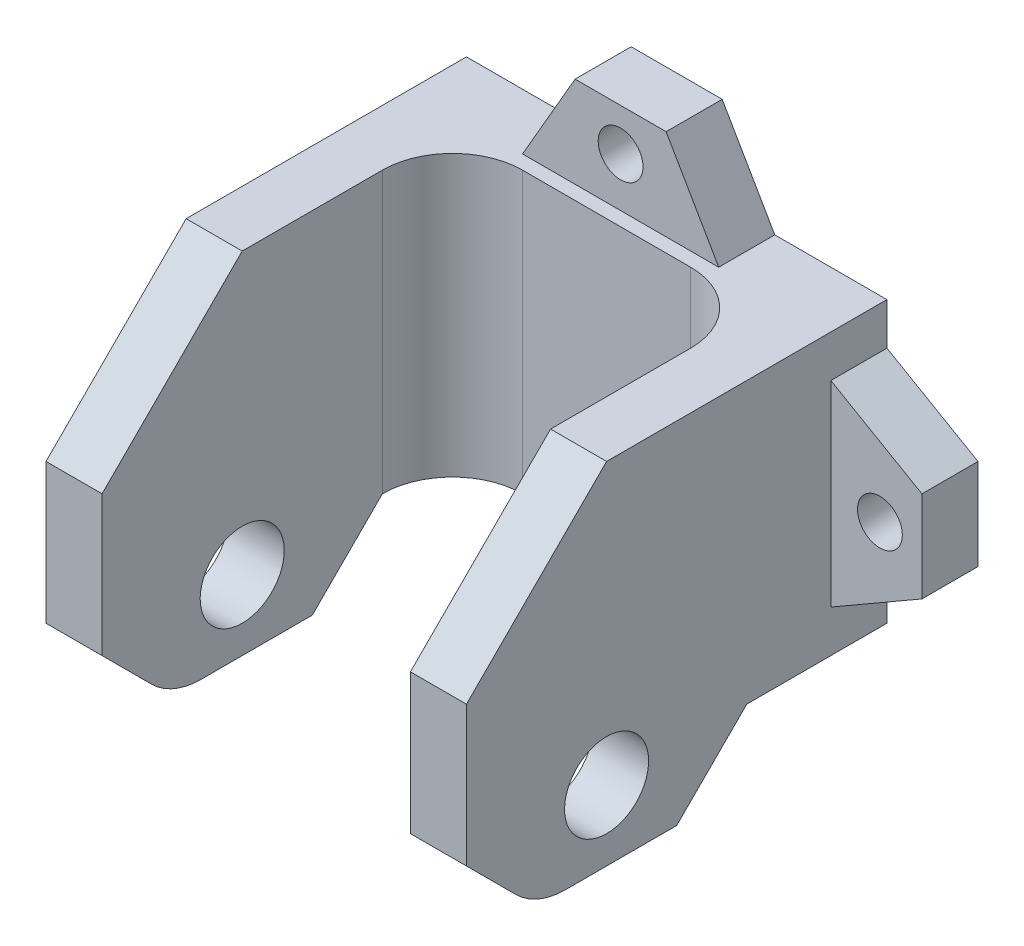
from build123d import *

# Parameters (mm, degrees)
SKETCH1_W             = 30
SKETCH1_H             = 40
BOSS_EXTRUDE1_DEPTH   = 5
SKETCH2_W             = 4
SKETCH2_H             = 40
BOSS_EXTRUDE2_DEPTH   = 25
CHAMFER1_SIZE         = 10
SKETCH3_R             = 3
CUT_EXTRUDE1_DEPTH    = 76
CUT_EXTRUDE2_DEPTH    = 76
CHAMFER2_SIZE         = 5
FILLET1_R             = 5
FILLET2_R             = 5
SKETCH5_R             = 1.6
BOSS_EXTRUDE3_DEPTH   = 4
BOSS_EXTRUDE3_2_DEPTH = 4
BOSS_EXTRUDE3_3_DEPTH = 4


with BuildPart() as part:
    # Sketch1 → Boss-Extrude1 (new body)
    with BuildSketch(Plane.XY):
        with Locations((0, -65)):
            Rectangle(SKETCH1_W, SKETCH1_H)
    extrude(amount=BOSS_EXTRUDE1_DEPTH)

    # Sketch2 → Boss-Extrude2 (add)
    with BuildSketch(Plane.XY.offset(5)):
        with Locations((-13, -65)):
            Rectangle(SKETCH2_W, SKETCH2_H)
        with Locations((13, -65)):
            Rectangle(SKETCH2_W, SKETCH2_H)
    extrude(amount=BOSS_EXTRUDE2_DEPTH)

    # Chamfer1
    chamfer1_edges = [part.edges().sort_by_distance(p)[0] for p in [
        (-13, -85, 30),
        (-13, -45, 30),
        (13, -45, 30),
        (13, -85, 30),
    ]]
    chamfer(chamfer1_edges, length=CHAMFER1_SIZE)

    # Sketch3 → Cut-Extrude1 (cut)
    with BuildSketch(Plane.ZY.offset(15)):
        with Locations((20, -65)):
            Circle(SKETCH3_R)
    extrude(amount=-CUT_EXTRUDE1_DEPTH, mode=Mode.SUBTRACT)

    # Sketch4 → Cut-Extrude2 (cut)
    with BuildSketch(Plane.ZY.offset(15)):
        Polygon((30, -70), (15, -70), (10, -65), (0, -65), (-4.906165795, -89.804855258), (31.217938956, -87.25505427), align=None)
    extrude(amount=-CUT_EXTRUDE2_DEPTH, mode=Mode.SUBTRACT)

    # Chamfer2
    chamfer2_edges = [part.edges().sort_by_distance(p)[0] for p in [
        (13, -70, 30),
        (-13, -70, 30),
    ]]
    chamfer(chamfer2_edges, length=CHAMFER2_SIZE)

    # Fillet1
    fillet1_edges = [part.edges().sort_by_distance(p)[0] for p in [
        (11, -55, 5),
        (-11, -55, 5),
    ]]
    fillet(fillet1_edges, radius=FILLET1_R)

    # Fillet2
    fillet2_edges = [part.edges().sort_by_distance(p)[0] for p in [
        (-13, -70, 25),
        (13, -70, 25),
    ]]
    fillet(fillet2_edges, radius=FILLET2_R)


with BuildPart() as body_2:
    # Sketch5 → Boss-Extrude3 (new body)
    with BuildSketch(Plane(origin=(0, 0, 0), x_dir=(-1, 0, 0), z_dir=(0, 0, -1))):
        Polygon((7, -45), (3.24722325, -38.5), (-3.24722325, -38.5), (-7, -45), align=None)
        with Locations((0, -41.5)):
            Circle(SKETCH5_R, mode=Mode.SUBTRACT)
    extrude(amount=-BOSS_EXTRUDE3_DEPTH)


with BuildPart() as body_3:
    # Sketch5 → Boss-Extrude3 2 (new body)
    with BuildSketch(Plane(origin=(0, 0, 0), x_dir=(-1, 0, 0), z_dir=(0, 0, -1))):
        Polygon((15, -48), (21.5, -51.75277675), (21.5, -58.24722325), (15, -62), align=None)
        with Locations((18.5, -55)):
            Circle(SKETCH5_R, mode=Mode.SUBTRACT)
    extrude(amount=-BOSS_EXTRUDE3_2_DEPTH)


with BuildPart() as body_4:
    # Sketch5 → Boss-Extrude3 3 (new body)
    with BuildSketch(Plane(origin=(0, 0, 0), x_dir=(-1, 0, 0), z_dir=(0, 0, -1))):
        Polygon((-15, -62), (-15, -48), (-21.5, -51.75277675), (-21.5, -58.24722325), align=None)
        with Locations((-18.5, -55)):
            Circle(SKETCH5_R, mode=Mode.SUBTRACT)
    extrude(amount=-BOSS_EXTRUDE3_3_DEPTH)


solid = Compound([part.part, body_2.part, body_3.part, body_4.part])
